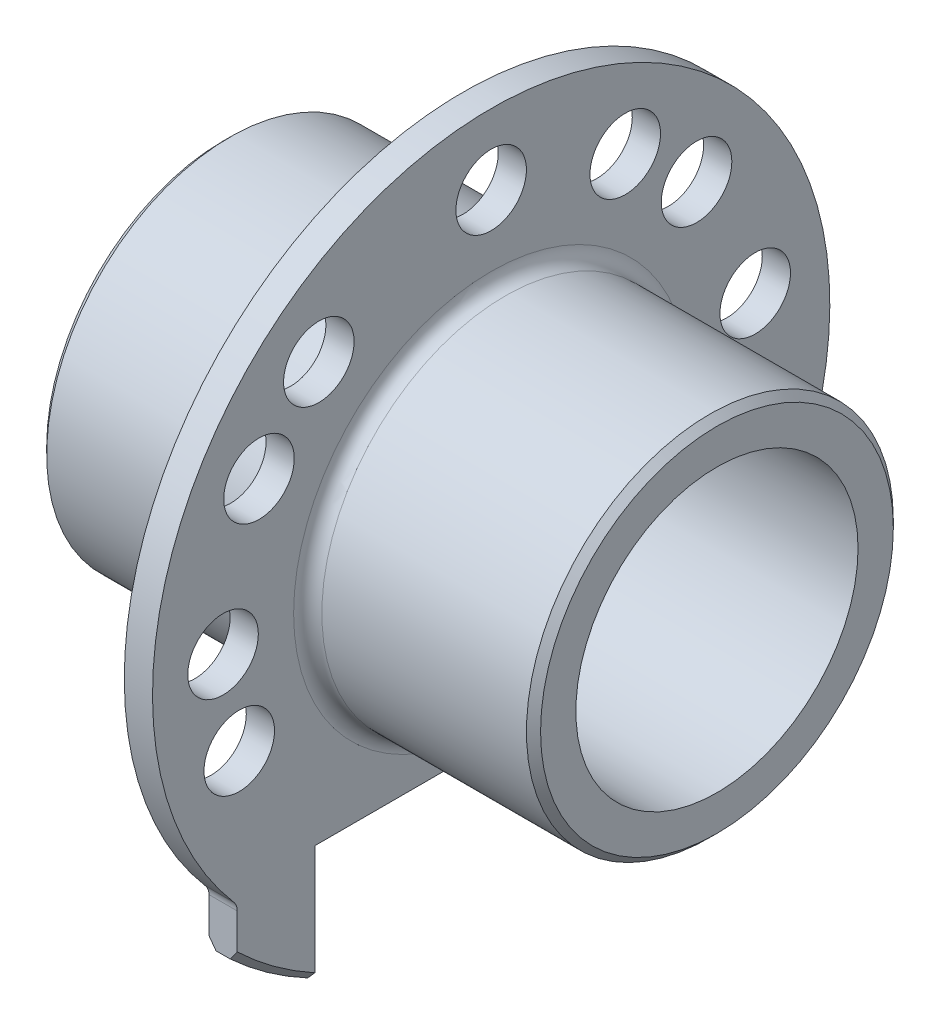
from build123d import *

# Parameters (mm, degrees)
SKETCH1_R                       = 13
BOSS_EXTRUDE1_DEPTH             = 17
SKETCH2_R                       = 26.5
BOSS_EXTRUDE2_DEPTH             = 1
CHAMFER1_SIZE                   = 0.5
WYTNIJ_WYCI_GNI_CIE1_DEPTH      = 42.152156687
WYTNIJ_WYCI_GNI_CIE1_DEPTH_BACK = 42.152156687
SKETCH4_R                       = 2.5
DODANIE_WYCI_GNI_CIE1_START     = -18
SKETCH1_3_R                     = 13
DODANIE_WYCI_GNI_CIE1_DEPTH     = 18
SZKIC5_R                        = 10
WYTNIJ_WYCI_GNI_CIE2_DEPTH      = 40
WYTNIJ_WYCI_GNI_CIE3_DEPTH      = 40
SFAZOWANIE1_SIZE                = 0.5
ZAOKR_GLENIE1_R                 = 1
SZKIC7_W                        = 25
SZKIC7_H                        = 18.250813048
WYTNIJ_WYCI_GNI_CIE4_DEPTH      = 10
ZAOKR_GLENIE2_R                 = 1


with BuildPart() as part:
    # Sketch1 → Boss-Extrude1 (new body)
    with BuildSketch(Plane(origin=(0, 0, 0), x_dir=(0, 0, -1), z_dir=(1, 0, 0))):
        Circle(SKETCH1_R)
    extrude(amount=BOSS_EXTRUDE1_DEPTH)

    # Sketch2 → Boss-Extrude2 (add, symmetric)
    with BuildSketch(Plane(origin=(0, 0, 0), x_dir=(0, 0, -1), z_dir=(1, 0, 0))):
        Circle(SKETCH2_R)
    extrude(amount=BOSS_EXTRUDE2_DEPTH, both=True)

    # Chamfer1
    chamfer1_edges = [part.edges().sort_by_distance(p)[0] for p in [
        (17, 0, 13),
        (1, 0, 26.5),
        (-1, 0, 26.5),
    ]]
    chamfer(chamfer1_edges, length=CHAMFER1_SIZE)

    # Sketch4 → Wytnij-wyci_gni_cie1 (cut, two sides: drawn at the far end of the back side and taken through both)
    with BuildSketch(Plane(origin=(0, 0, 0), x_dir=(0, 0, -1), z_dir=(1, 0, 0)).offset(-WYTNIJ_WYCI_GNI_CIE1_DEPTH_BACK)):
        with Locations((17.219847954, -8.029746973)):
            Circle(SKETCH4_R)
        with Locations((-19, 0)):
            Circle(SKETCH4_R)
        with Locations((14.554844419, 12.212964584)):
            Circle(SKETCH4_R)
        with Locations((0, 19)):
            Circle(SKETCH4_R)
        with Locations((-17.854159795, -6.498382723)):
            Circle(SKETCH4_R)
        with Locations((-16.454482672, 9.5)):
            Circle(SKETCH4_R)
        with Locations((18.711347307, 3.299315376)):
            Circle(SKETCH4_R)
        with Locations((-12.212964584, 14.554844419)):
            Circle(SKETCH4_R)
        with Locations((9.5, 16.454482672)):
            Circle(SKETCH4_R)
    extrude(amount=WYTNIJ_WYCI_GNI_CIE1_DEPTH + WYTNIJ_WYCI_GNI_CIE1_DEPTH_BACK, mode=Mode.SUBTRACT)

    # Sketch1_3 → Dodanie-wyci_gni_cie1 (add)
    with BuildSketch(Plane(origin=(0, 0, 0), x_dir=(0, 0, -1), z_dir=(1, 0, 0)).offset(DODANIE_WYCI_GNI_CIE1_START)):
        Circle(SKETCH1_3_R)
    extrude(amount=DODANIE_WYCI_GNI_CIE1_DEPTH)

    # Szkic5 → Wytnij-wyci_gni_cie2 (cut)
    with BuildSketch(Plane(origin=(17, 0, 0), x_dir=(0, 0, -1), z_dir=(1, 0, 0))):
        Circle(SZKIC5_R)
    extrude(amount=-WYTNIJ_WYCI_GNI_CIE2_DEPTH, mode=Mode.SUBTRACT)

    # Szkic4 → Wytnij-wyci_gni_cie3 (cut)
    with BuildSketch(Plane.ZY.offset(1)):
        with BuildLine():
            Line((18, -15.874507866), (18, -28.40570104))
            Line((18, -28.40570104), (34.562586152, -28.40570104))
            Line((34.562586152, -28.40570104), (34.562586152, 27.915934969))
            Line((34.562586152, 27.915934969), (-37.904902175, 28.979399158))
            Line((-37.904902175, 28.979399158), (-37.904902175, -27.460164602))
            Line((-37.904902175, -27.460164602), (-18, -25.464511286))
            Line((-18, -25.464511286), (-18, -15.874507866))
            ThreePointArc((-18, -15.874507866), (0, 24), (18, -15.874507866))
        make_face()
    extrude(amount=-WYTNIJ_WYCI_GNI_CIE3_DEPTH, mode=Mode.SUBTRACT)

    # Sfazowanie1
    sfazowanie1_edges = [part.edges().sort_by_distance(p)[0] for p in [
        (-18, 0, 13),
    ]]
    chamfer(sfazowanie1_edges, length=SFAZOWANIE1_SIZE)

    # Zaokr_glenie1
    zaokr_glenie1_edges = [part.edges().sort_by_distance(p)[0] for p in [
        (1, 0, 13),
        (-1, 0, 13),
    ]]
    fillet(zaokr_glenie1_edges, radius=ZAOKR_GLENIE1_R)

    # Szkic7 → Wytnij-wyci_gni_cie4 (cut)
    with BuildSketch(Plane.ZY.offset(1)):
        with Locations((0, -24.125406524)):
            Rectangle(SZKIC7_W, SZKIC7_H)
    extrude(amount=-WYTNIJ_WYCI_GNI_CIE4_DEPTH, mode=Mode.SUBTRACT)

    # Zaokr_glenie2
    zaokr_glenie2_edges = [part.edges().sort_by_distance(p)[0] for p in [
        (0, -15.874507866, -18),
        (0, -15.874507866, 18),
    ]]
    fillet(zaokr_glenie2_edges, radius=ZAOKR_GLENIE2_R)


solid = part.part
